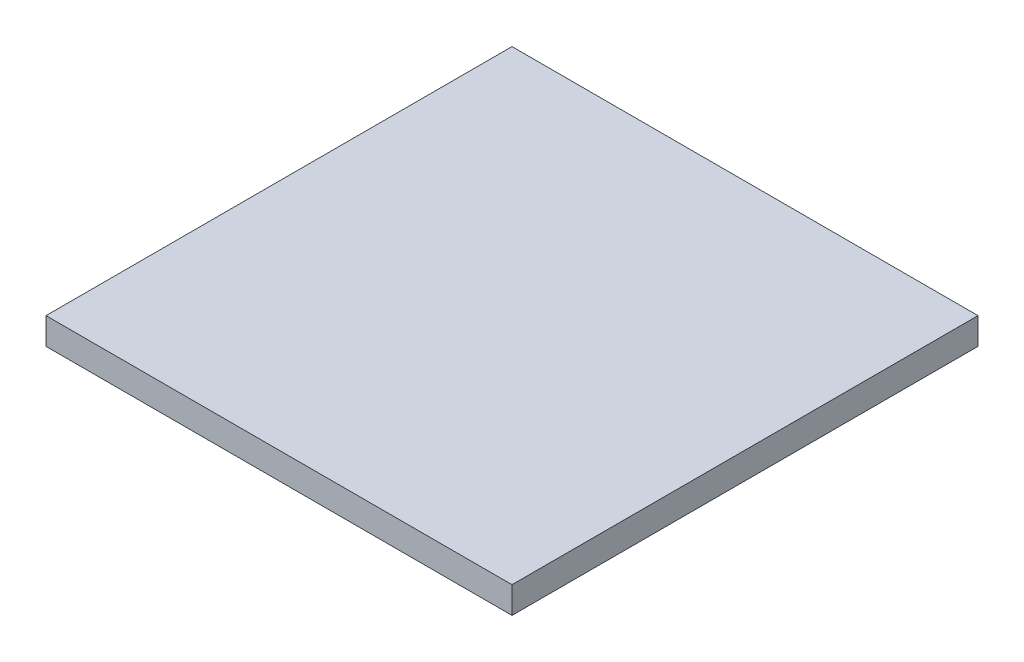
from build123d import *

# Parameters (mm, degrees)
SKETCH_1_W      = 35
SKETCH_1_H      = 35
EXTRUDE_1_DEPTH = 2


with BuildPart() as part:
    # 草图1 → 凸台-拉伸1 (new body)
    with BuildSketch(Plane(origin=(0, 0, 0), x_dir=(1, 0, 0), z_dir=(0, 1, 0))):
        Rectangle(SKETCH_1_W, SKETCH_1_H)
    extrude(amount=EXTRUDE_1_DEPTH)


solid = part.part
